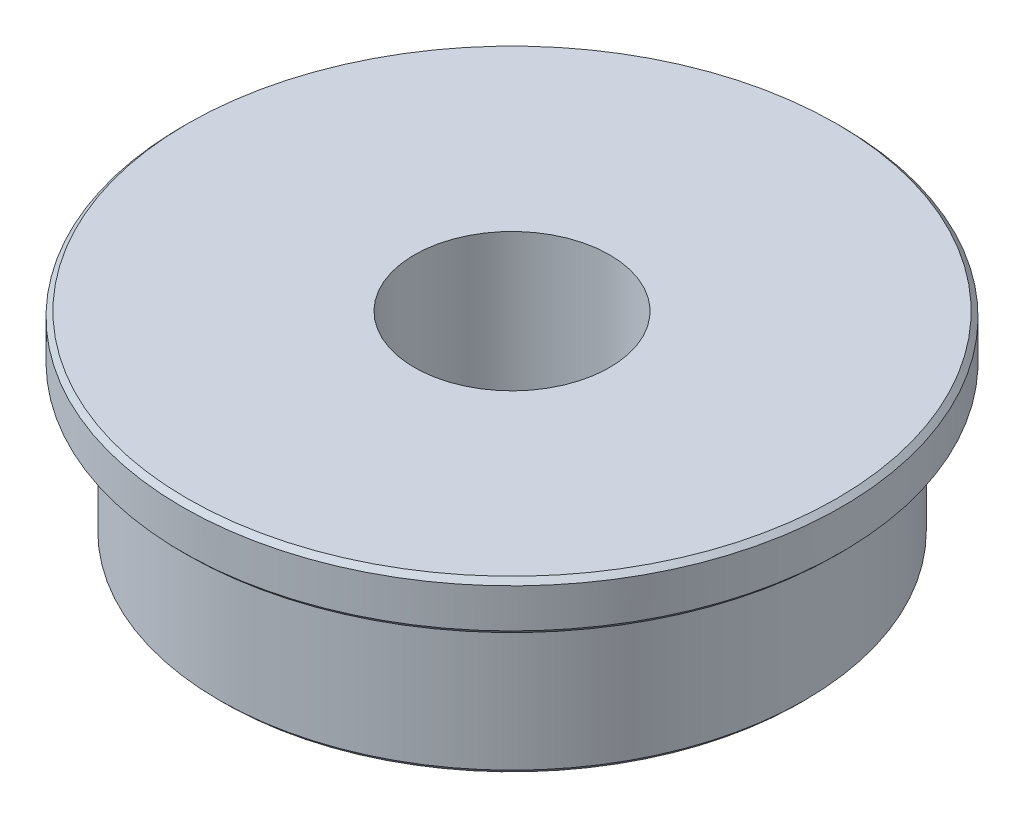
from build123d import *

# Parameters (mm, degrees)
CHAMFER_1_SIZE = 0.1


with BuildPart() as part:
    # 草图1 → 旋转1 (revolve)
    with BuildSketch(Plane.XY):
        Polygon((2, 0), (2, 4), (6.75, 4), (6.75, 3), (6, 3), (6, 0), align=None)
    revolve(axis=Axis((0, 0, 0), (0, 1, 0)))

    # 倒角1
    chamfer_1_edges = [part.edges().sort_by_distance(p)[0] for p in [
        (-6, 0, 0),
        (-6.75, 3, 0),
        (-6.75, 4, 0),
    ]]
    chamfer(chamfer_1_edges, length=CHAMFER_1_SIZE)


solid = part.part
